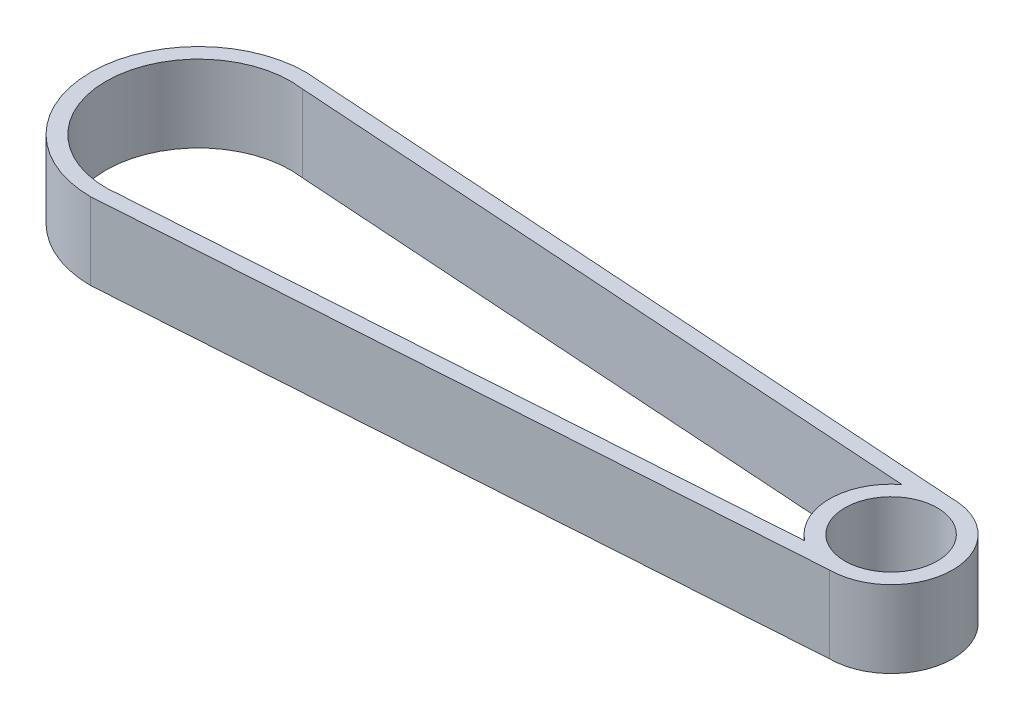
from build123d import *

# Parameters (mm, degrees)
SKETCH1_R           = 6
BOSS_EXTRUDE1_DEPTH = 10


with BuildPart() as part:
    # Sketch1 → Boss-Extrude1 (new body)
    with BuildSketch(Plane(origin=(0, 0, 0), x_dir=(1, 0, 0), z_dir=(0, 1, 0))):
        with BuildLine():
            ThreePointArc((0, 14), (-14, 0), (0, -14))
            Line((0, -14), (90, -8))
            ThreePointArc((90, -8), (98, 0), (90, 8))
            Line((90, 8), (0, 14))
        make_face()
        with BuildLine():
            ThreePointArc((1.65636135, -11.885136393), (0.798228126, -11.973421894), (-0.064030313, -11.99982917))
            ThreePointArc((-0.064030313, -11.99982917), (-12, 0), (-0.064030313, 11.99982917))
            ThreePointArc((-0.064030313, 11.99982917), (0.798228126, 11.973421894), (1.65636135, 11.885136393))
            Line((1.65636135, 11.885136393), (85.098173392, 6.322348923))
            ThreePointArc((85.098173392, 6.322348923), (82, 0), (85.098173392, -6.322348923))
            Line((85.098173392, -6.322348923), (1.65636135, -11.885136393))
        make_face(mode=Mode.SUBTRACT)
        with Locations((90, 0)):
            Circle(SKETCH1_R, mode=Mode.SUBTRACT)
    extrude(amount=BOSS_EXTRUDE1_DEPTH)


solid = part.part
